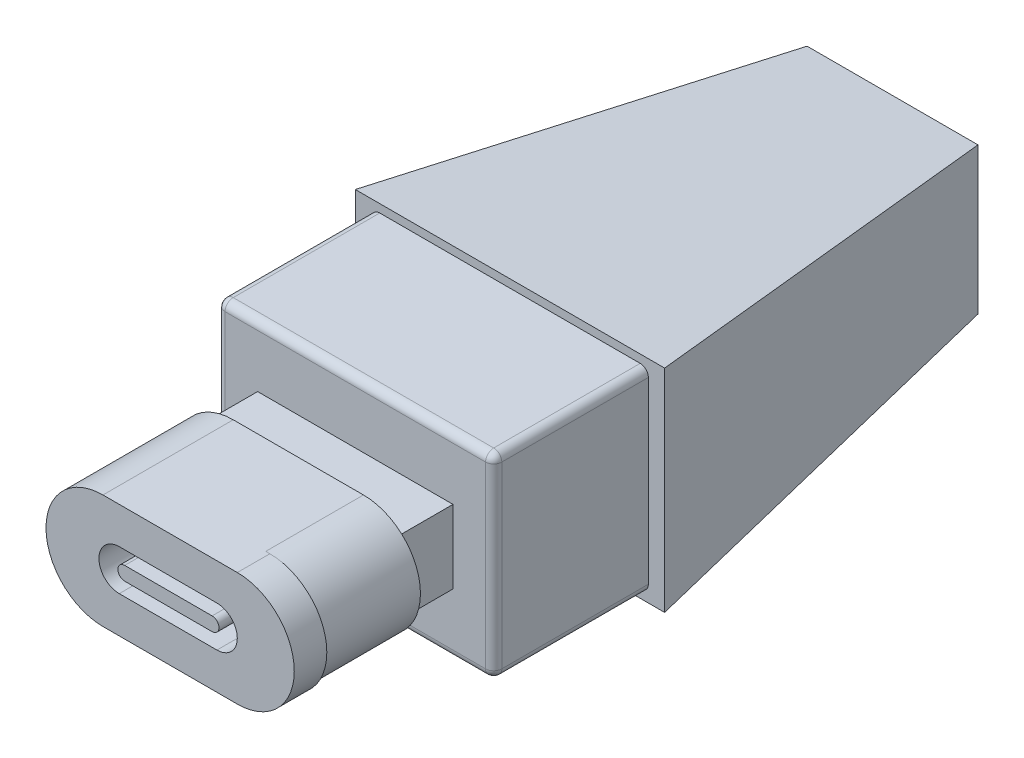
from build123d import *

# Parameters (mm, degrees)
SALIENTE_EXTRUIR1_DEPTH = 6
SALIENTE_EXTRUIR2_DEPTH = 2
CROQUIS3_W              = 12
CROQUIS3_H              = 4.5
SALIENTE_EXTRUIR3_DEPTH = 3.5
CROQUIS4_W              = 17
CROQUIS4_H              = 12
SALIENTE_EXTRUIR4_DEPTH = 9.5
CROQUIS5_W              = 19
CROQUIS5_H              = 13
CROQUIS6_W              = 10.5
CROQUIS6_H              = 9
REDONDEO1_R             = 0.5
CORTAR_EXTRUIR1_DEPTH   = 3
SALIENTE_EXTRUIR5_DEPTH = 3


with BuildPart() as part:
    # Croquis1 → Saliente-Extruir1 (new body)
    with BuildSketch(Plane.XY):
        with BuildLine():
            Line((-4, 3.5), (4, 3.5))
            ThreePointArc((4, 3.5), (7.5, 0), (4, -3.5))
            Line((4, -3.5), (-4, -3.5))
            ThreePointArc((-4, -3.5), (-7.5, 0), (-4, 3.5))
        make_face()
    extrude(amount=SALIENTE_EXTRUIR1_DEPTH)

    # Croquis2 → Saliente-Extruir2 (add)
    with BuildSketch(Plane.XY.offset(6)):
        with BuildLine():
            Line((-4, 3.5), (4.25, 3.5))
            ThreePointArc((4.25, 3.5), (7.75, 0), (4.25, -3.5))
            Line((4.25, -3.5), (-4, -3.5))
            ThreePointArc((-4, -3.5), (-7.5, 0), (-4, 3.5))
        make_face()
    extrude(amount=SALIENTE_EXTRUIR2_DEPTH)

    # Croquis3 → Saliente-Extruir3 (add)
    with BuildSketch(Plane(origin=(0, 0, 0), x_dir=(-1, 0, 0), z_dir=(0, 0, -1))):
        Rectangle(CROQUIS3_W, CROQUIS3_H)
    extrude(amount=SALIENTE_EXTRUIR3_DEPTH)

    # Croquis4 → Saliente-Extruir4 (add)
    with BuildSketch(Plane(origin=(0, 0, -3.5), x_dir=(-1, 0, 0), z_dir=(0, 0, -1))):
        Rectangle(CROQUIS4_W, CROQUIS4_H)
    extrude(amount=SALIENTE_EXTRUIR4_DEPTH)

    # Croquis5 → Recubrir1 section 0
    with BuildSketch(Plane(origin=(0, 0, -13), x_dir=(-1, 0, 0), z_dir=(0, 0, -1))):
        Rectangle(CROQUIS5_W, CROQUIS5_H)
    # Croquis6 → Recubrir1 section 1
    with BuildSketch(Plane(origin=(0, 0, -36.5), x_dir=(-1, 0, 0), z_dir=(0, 0, -1))):
        Rectangle(CROQUIS6_W, CROQUIS6_H)
    loft()

    # Redondeo1
    redondeo1_edges = [part.edges().sort_by_distance(p)[0] for p in [
        (-8.5, 0, -3.5),
        (-8.5, -6, -8.25),
        (0, 6, -3.5),
        (-8.5, 6, -8.25),
        (8.5, 0, -3.5),
        (8.5, 6, -8.25),
        (0, -6, -3.5),
        (8.5, -6, -8.25),
    ]]
    fillet(redondeo1_edges, radius=REDONDEO1_R)

    # Croquis7 → Cortar-Extruir1 (cut)
    with BuildSketch(Plane.XY.offset(8)):
        with BuildLine():
            Line((-3, 1.25), (3, 1.25))
            ThreePointArc((3, 1.25), (4.25, 0), (3, -1.25))
            Line((3, -1.25), (-3, -1.25))
            ThreePointArc((-3, -1.25), (-4.25, 0), (-3, 1.25))
        make_face()
    extrude(amount=-CORTAR_EXTRUIR1_DEPTH, mode=Mode.SUBTRACT)

    # Croquis8 → Saliente-Extruir5 (add)
    with BuildSketch(Plane.XY.offset(5)):
        with BuildLine():
            Line((-2.665643122, 0.419863202), (2.704700164, 0.419863202))
            ThreePointArc((2.704700164, 0.419863202), (3.124563366, 0), (2.704700164, -0.419863202))
            Line((2.704700164, -0.419863202), (-2.665643122, -0.419863202))
            ThreePointArc((-2.665643122, -0.419863202), (-3.085506324, 0), (-2.665643122, 0.419863202))
        make_face()
    extrude(amount=SALIENTE_EXTRUIR5_DEPTH)


solid = part.part
